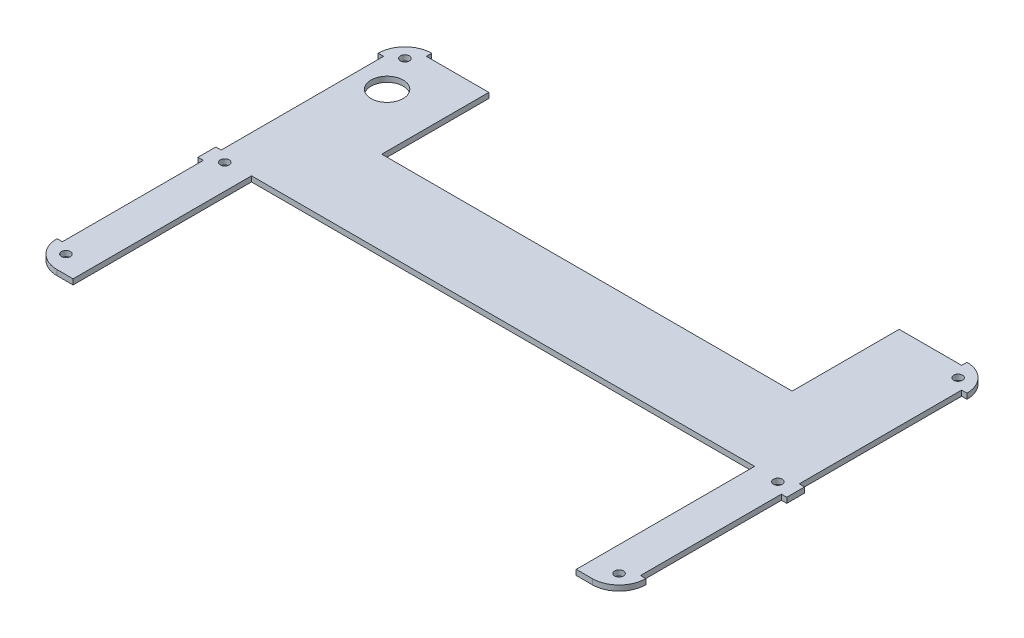
from build123d import *

# Parameters (mm, degrees)
ESQUISSE1_R      = 2.5
ESQUISSE1_R_2    = 9
EXTRUSION1_DEPTH = 3
CONG_1_R         = 15
EXTRUSION2_REACH = 5
ESQUISSE2_W      = 300
ESQUISSE2_H      = 3
ESQUISSE2_W_2    = 3
ESQUISSE2_H_2    = 91
ESQUISSE2_H_3    = 79
EXTRUSION3_REACH = 5
ESQUISSE3_W      = 230
ESQUISSE3_H      = 60


with BuildPart() as part:
    # Esquisse1 → Extrusion1 (new body)
    with BuildSketch(Plane(origin=(0, 0, 0), x_dir=(1, 0, 0), z_dir=(0, 1, 0))):
        Polygon((0, 0), (24, 0), (24, 100), (165, 100), (306, 100), (306, 0), (330, 0), (330, 210), (0, 210), align=None)
        with Locations((10, 200)):
            Circle(ESQUISSE1_R, mode=Mode.SUBTRACT)
        with Locations((320, 200)):
            Circle(ESQUISSE1_R, mode=Mode.SUBTRACT)
        with Locations((10, 99)):
            Circle(ESQUISSE1_R, mode=Mode.SUBTRACT)
        with Locations((320, 99)):
            Circle(ESQUISSE1_R, mode=Mode.SUBTRACT)
        with Locations((10, 10)):
            Circle(ESQUISSE1_R, mode=Mode.SUBTRACT)
        with Locations((320, 10)):
            Circle(ESQUISSE1_R, mode=Mode.SUBTRACT)
        with Locations((20, 180)):
            Circle(ESQUISSE1_R_2, mode=Mode.SUBTRACT)
    extrude(amount=EXTRUSION1_DEPTH)

    # Congé1
    cong_1_edges = [part.edges().sort_by_distance(p)[0] for p in [
        (0, 1.5, -210),
        (330, 1.5, -210),
        (330, 1.5, 0),
        (0, 1.5, 0),
    ]]
    fillet(cong_1_edges, radius=CONG_1_R)

    # Esquisse2 → Extrusion2 (cut, up to next)
    with BuildSketch(Plane(origin=(0, 3, 0), x_dir=(1, 0, 0), z_dir=(0, 1, 0)), mode=Mode.PRIVATE) as extrusion2_sk1:
        with Locations((165, 208.5)):
            Rectangle(ESQUISSE2_W, ESQUISSE2_H)
    extrusion2_tool1 = extrude(extrusion2_sk1.sketch, amount=-EXTRUSION2_REACH, mode=Mode.PRIVATE) & part.part
    add(extrusion2_tool1.solids().sort_by_distance((165, 3, -208.5))[0], mode=Mode.SUBTRACT)
    # Esquisse2 → Extrusion2 (cut, up to next)
    with BuildSketch(Plane(origin=(0, 3, 0), x_dir=(1, 0, 0), z_dir=(0, 1, 0)), mode=Mode.PRIVATE) as extrusion2_sk2:
        with Locations((1.5, 149.5)):
            Rectangle(ESQUISSE2_W_2, ESQUISSE2_H_2)
    extrusion2_tool2 = extrude(extrusion2_sk2.sketch, amount=-EXTRUSION2_REACH, mode=Mode.PRIVATE) & part.part
    add(extrusion2_tool2.solids().sort_by_distance((1.5, 3, -149.5))[0], mode=Mode.SUBTRACT)
    # Esquisse2 → Extrusion2 (cut, up to next)
    with BuildSketch(Plane(origin=(0, 3, 0), x_dir=(1, 0, 0), z_dir=(0, 1, 0)), mode=Mode.PRIVATE) as extrusion2_sk3:
        with Locations((1.5, 54.5)):
            Rectangle(ESQUISSE2_W_2, ESQUISSE2_H_3)
    extrusion2_tool3 = extrude(extrusion2_sk3.sketch, amount=-EXTRUSION2_REACH, mode=Mode.PRIVATE) & part.part
    add(extrusion2_tool3.solids().sort_by_distance((1.5, 3, -54.5))[0], mode=Mode.SUBTRACT)
    # Esquisse2 → Extrusion2 (cut, up to next)
    with BuildSketch(Plane(origin=(0, 3, 0), x_dir=(1, 0, 0), z_dir=(0, 1, 0)), mode=Mode.PRIVATE) as extrusion2_sk4:
        with Locations((328.5, 54.5)):
            Rectangle(ESQUISSE2_W_2, ESQUISSE2_H_3)
    extrusion2_tool4 = extrude(extrusion2_sk4.sketch, amount=-EXTRUSION2_REACH, mode=Mode.PRIVATE) & part.part
    add(extrusion2_tool4.solids().sort_by_distance((328.5, 3, -54.5))[0], mode=Mode.SUBTRACT)
    # Esquisse2 → Extrusion2 (cut, up to next)
    with BuildSketch(Plane(origin=(0, 3, 0), x_dir=(1, 0, 0), z_dir=(0, 1, 0)), mode=Mode.PRIVATE) as extrusion2_sk5:
        with Locations((328.5, 149.5)):
            Rectangle(ESQUISSE2_W_2, ESQUISSE2_H_2)
    extrusion2_tool5 = extrude(extrusion2_sk5.sketch, amount=-EXTRUSION2_REACH, mode=Mode.PRIVATE) & part.part
    add(extrusion2_tool5.solids().sort_by_distance((328.5, 3, -149.5))[0], mode=Mode.SUBTRACT)

    # Esquisse3 → Extrusion3 (cut, up to next)
    with BuildSketch(Plane(origin=(0, 3, 0), x_dir=(1, 0, 0), z_dir=(0, 1, 0)), mode=Mode.PRIVATE) as extrusion3_sk1:
        with Locations((165, 177)):
            Rectangle(ESQUISSE3_W, ESQUISSE3_H)
    extrusion3_tool1 = extrude(extrusion3_sk1.sketch, amount=-EXTRUSION3_REACH, mode=Mode.PRIVATE) & part.part
    add(extrusion3_tool1.solids().sort_by_distance((165, 3, -177))[0], mode=Mode.SUBTRACT)


solid = part.part
